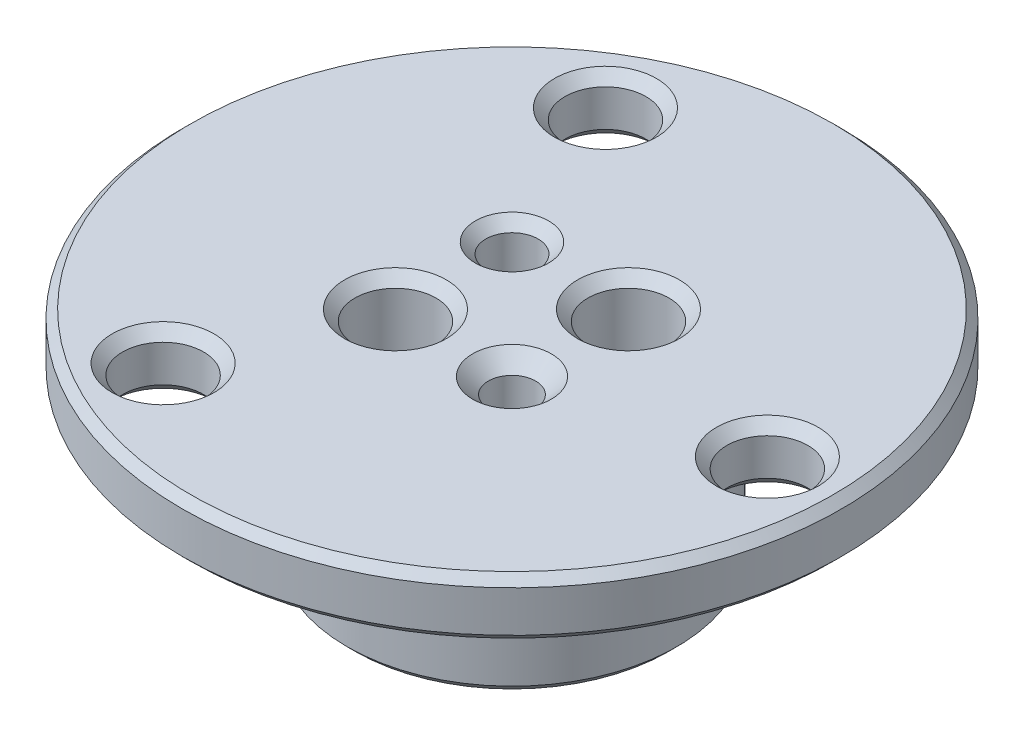
from build123d import *

# Parameters (mm, degrees)
F_8_CLEARANCE_HOLE2_AT_2_COUNT = 2
F_8_CLEARANCE_HOLE2_AT_2_PITCH = 10
F_8_CLEARANCE_HOLE1_AT_2_COUNT = 2
F_8_CLEARANCE_HOLE1_AT_2_PITCH = 26.846787517
F_8_CLEARANCE_HOLE1_AT_3_COUNT = 2
F_8_CLEARANCE_HOLE1_AT_3_PITCH = 26.846787517
CHAMFER1_SIZE                  = 0.5
FILLET1_R                      = 0.5


with BuildPart() as part:
    # Sketch1 → Revolve1 (revolve)
    with BuildSketch(Plane(origin=(0, 0, 0), x_dir=(0, 0, -1), z_dir=(1, 0, 0)), mode=Mode.PRIVATE) as revolve1_sk:
        Polygon((0, 0), (0, 13.2432806), (20, 13.2432806), (20, 9.7432806), (10, 9.7432806), (10, 0), align=None)
    revolve(revolve1_sk.sketch.rotate(Axis((0, 0, 0), (0, -1, 0)), 180), axis=Axis((0, 0, 0), (0, -1, 0)))  # turned: the seam where the file's is

    # Sketch4 → #8 Clearance Hole2 (revolve, cut)
    with BuildSketch(Plane(origin=(3.535533906, 13.2432806, -3.535533906), x_dir=(0, 0, 1), z_dir=(1, 0, 0))):
        Polygon((0, 0), (0, 13.2432806), (3.09245, 13.2432806), (2.45745, 12.6082806), (2.45745, 0.635), (3.09245, 0), align=None)
    f_8_clearance_hole2 = revolve(axis=Axis((3.535533906, 19.5932806, -3.535533906), (0, -1, 0)), mode=Mode.SUBTRACT)

    # #8 Clearance Hole2 at 2: #8 Clearance Hole2 ×2
    with Locations(*[Vector(-0.707106781, 0, 0.707106781) * (i * F_8_CLEARANCE_HOLE2_AT_2_PITCH) for i in range(1, F_8_CLEARANCE_HOLE2_AT_2_COUNT)]):
        add(f_8_clearance_hole2, mode=Mode.SUBTRACT)

    # Sketch5 → 1/8 (0.125) Diameter Hole1 (revolve, cut)
    with BuildSketch(Plane(origin=(-3.535533906, 13.2432806, -3.535533906), x_dir=(0, 0, 1), z_dir=(1, 0, 0))):
        Polygon((0, 0), (0, 13.2432806), (2.2225, 13.2432806), (1.5875, 12.6082806), (1.5875, 0.635), (2.2225, 0), align=None)
    revolve(axis=Axis((-3.535533906, 19.5932806, -3.535533906), (0, -1, 0)), mode=Mode.SUBTRACT)

    # Sketch8 → #8 Clearance Hole1 (revolve, cut)
    with BuildSketch(Plane(origin=(-7.75, 13.2432806, -13.423393759), x_dir=(0, 0, 1), z_dir=(1, 0, 0))):
        Polygon((0, 0), (0, 3.5), (3.0861, 3.5), (2.45745, 2.87135), (2.45745, 0.635), (3.09245, 0), align=None)
    f_8_clearance_hole1 = revolve(axis=Axis((-7.75, 19.5932806, -13.423393759), (0, -1, 0)), mode=Mode.SUBTRACT)

    # #8 Clearance Hole1 at 2: #8 Clearance Hole1 ×2
    with Locations(*[Vector(0.866025404, 0, 0.5) * (i * F_8_CLEARANCE_HOLE1_AT_2_PITCH) for i in range(1, F_8_CLEARANCE_HOLE1_AT_2_COUNT)]):
        add(f_8_clearance_hole1, mode=Mode.SUBTRACT)

    # #8 Clearance Hole1 at 3: #8 Clearance Hole1 ×2
    with Locations(*[(0, 0, i * F_8_CLEARANCE_HOLE1_AT_3_PITCH) for i in range(1, F_8_CLEARANCE_HOLE1_AT_3_COUNT)]):
        add(f_8_clearance_hole1, mode=Mode.SUBTRACT)

    # Sketch10 → #6-40 Tapped Hole1 (revolve, cut)
    with BuildSketch(Plane(origin=(3.535533906, 13.2432806, 3.535533906), x_dir=(0, 0, 1), z_dir=(1, 0, 0))):
        Polygon((0, 0), (0, 13.2432806), (2.3876, 13.2432806), (1.4351, 12.2907806), (1.4351, 0.9525), (2.3876, 0), align=None)
    revolve(axis=Axis((3.535533906, 19.5932806, 3.535533906), (0, -1, 0)), mode=Mode.SUBTRACT)

    # Chamfer1
    chamfer1_edges = [part.edges().sort_by_distance(p)[0] for p in [
        (0, 0, -10),
        (0, 9.7432806, -20),
        (0, 13.2432806, -20),
    ]]
    chamfer(chamfer1_edges, length=CHAMFER1_SIZE)

    # Fillet1
    fillet1_edges = [part.edges().sort_by_distance(p)[0] for p in [
        (0, 9.7432806, -10),
    ]]
    fillet(fillet1_edges, radius=FILLET1_R)


solid = part.part
